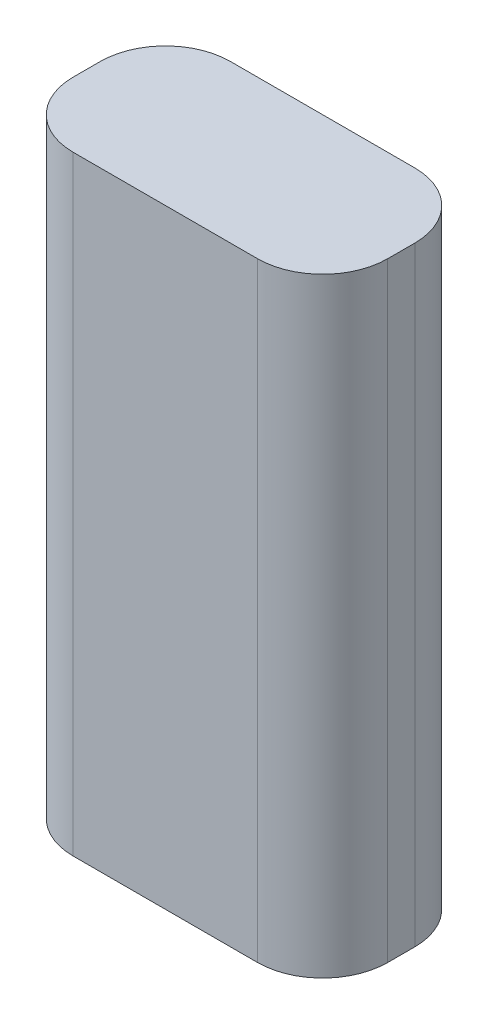
from build123d import *

# Parameters (mm, degrees)
SKETCH1_W           = 36.83
SKETCH1_H           = 71.374
BOSS_EXTRUDE1_DEPTH = 18.415
FILLET1_R           = 7.62


with BuildPart() as part:
    # Sketch1 → Boss-Extrude1 (new body)
    with BuildSketch(Plane.XY):
        with Locations((18.415, -35.687)):
            Rectangle(SKETCH1_W, SKETCH1_H)
    extrude(amount=BOSS_EXTRUDE1_DEPTH)

    # Fillet1
    fillet1_edges = [part.edges().sort_by_distance(p)[0] for p in [
        (36.83, -35.687, 18.415),
        (0, -35.687, 18.415),
        (36.83, -35.687, 0),
        (0, -35.687, 0),
    ]]
    fillet(fillet1_edges, radius=FILLET1_R)


solid = part.part
